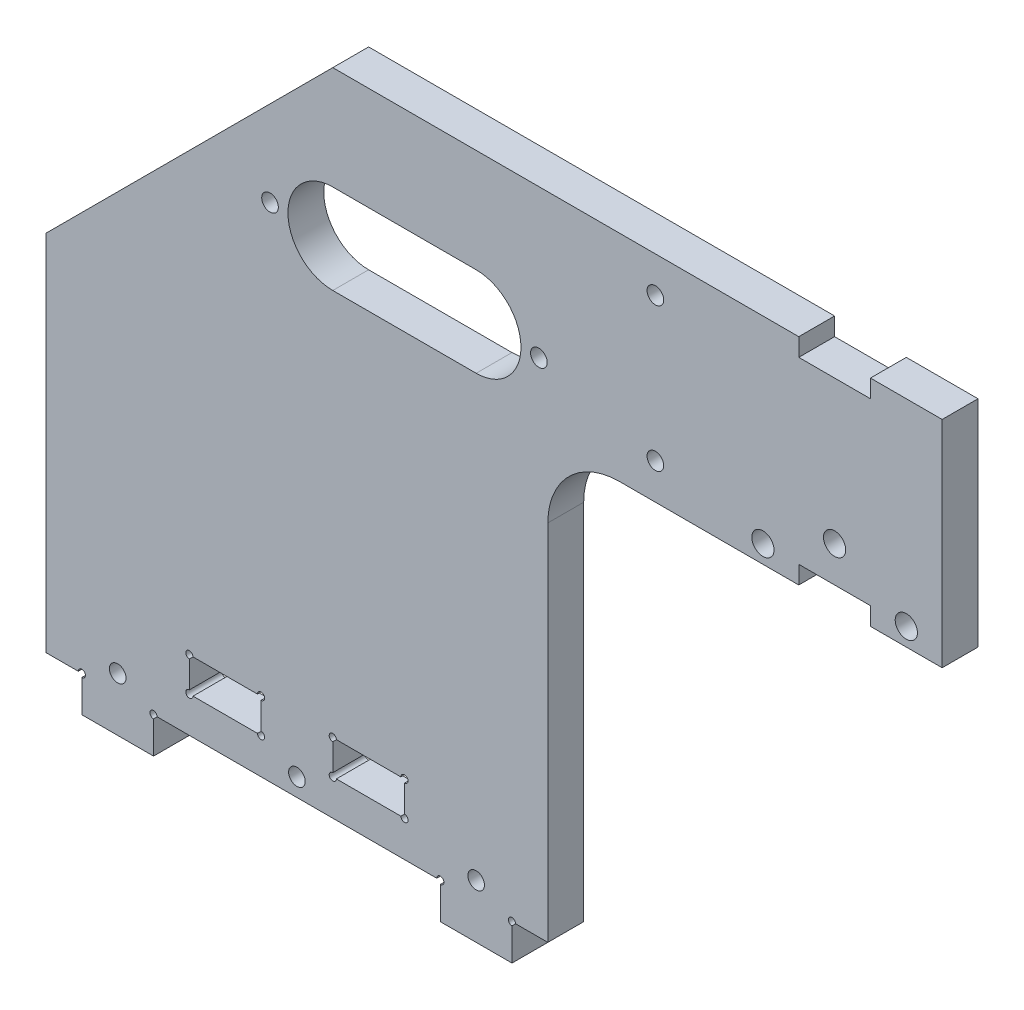
from build123d import *

# Parameters (mm, degrees)
SKETCH1_W                 = 12.7
SKETCH1_H                 = 6.0198
BOSS_EXTRUDE1_DEPTH       = 6.35
SKETCH13_R                = 0.635
CUT_EXTRUDE2_DEPTH        = 6.35
CHAMFER1_SIZE             = 50.8
FILLET2_R                 = 12.7
F_4_CLEARANCE_HOLE1_D     = 2.9464
F_4_CLEARANCE_HOLE1_DEPTH = 6.35
F_4_CLEARANCE_HOLE1_TIP   = 0.885187864
CUT_EXTRUDE3_REACH        = 164.372
SKETCH14_R                = 1.9685
F_4_CLEARANCE_HOLE2_D     = 2.9464
F_4_CLEARANCE_HOLE2_DEPTH = 6.35
F_4_CLEARANCE_HOLE2_TIP   = 0.885187864
CUT_EXTRUDE4_REACH        = 164.372
F_4_CLEARANCE_HOLE3_D     = 2.9464
F_4_CLEARANCE_HOLE3_DEPTH = 6.35
F_4_CLEARANCE_HOLE3_TIP   = 0.885187864


with BuildPart() as part:
    # Sketch1 → Boss-Extrude1 (new body)
    with BuildSketch(Plane.XY):
        Polygon((-25.4, 0), (25.4, 0), (25.4, -6.35), (38.1, -6.35), (38.1, 0), (44.45, 0), (44.45, 77.052), (88.9, 77.052), (88.9, 80.227), (101.6, 80.227), (101.6, 77.052), (114.3, 77.052), (114.3, 115.152), (101.6, 115.152), (101.6, 111.977), (88.9, 111.977), (88.9, 115.152), (-44.45, 115.152), (-44.45, 0), (-38.1, 0), (-38.1, -6.35), (-25.4, -6.35), align=None)
        with Locations((12.7, 9.3599)):
            Rectangle(SKETCH1_W, SKETCH1_H, mode=Mode.SUBTRACT)
        with Locations((-12.7, 9.3599)):
            Rectangle(SKETCH1_W, SKETCH1_H, mode=Mode.SUBTRACT)
    extrude(amount=BOSS_EXTRUDE1_DEPTH)

    # Sketch13 → Cut-Extrude2 (cut)
    with BuildSketch(Plane.XY):
        with Locations((-19.05, 12.3698)):
            Circle(SKETCH13_R)
    cut_extrude2 = extrude(amount=CUT_EXTRUDE2_DEPTH, mode=Mode.SUBTRACT)

    # Sketch-Pattern1: Cut-Extrude2 at 11 more places
    with Locations((12.7, 0, 0), (12.7, -6.0198, 0), (0, -6.0198, 0), (25.4, 0, 0), (38.1, 0, 0), (38.1, -6.0198, 0), (25.4, -6.0198, 0), (57.15, -12.3698, 0), (44.45, -12.3698, 0), (-6.35, -12.3698, 0), (-19.05, -12.3698, 0)):
        add(cut_extrude2, mode=Mode.SUBTRACT)

    # Chamfer1
    chamfer1_edges = [part.edges().sort_by_distance(p)[0] for p in [
        (-44.45, 115.152, 3.175),
    ]]
    chamfer(chamfer1_edges, length=CHAMFER1_SIZE)

    # Fillet2
    fillet2_edges = [part.edges().sort_by_distance(p)[0] for p in [
        (44.45, 77.052, 3.175),
    ]]
    fillet(fillet2_edges, radius=FILLET2_R)

    # #4 Clearance Hole1
    with Locations(Plane.XY.offset(6.35)):
        with Locations((-31.75, 3.175), (31.75, 3.175), (0, 3.175)):
            Hole(F_4_CLEARANCE_HOLE1_D / 2, depth=F_4_CLEARANCE_HOLE1_DEPTH)
            with Locations((0, 0, -(F_4_CLEARANCE_HOLE1_DEPTH + F_4_CLEARANCE_HOLE1_TIP / 2))):  # 118° drill point
                Cone(0, F_4_CLEARANCE_HOLE1_D / 2, F_4_CLEARANCE_HOLE1_TIP, mode=Mode.SUBTRACT)

    # Sketch14 → Cut-Extrude3 (cut, up to next)
    with BuildSketch(Plane.XY.offset(6.35), mode=Mode.PRIVATE) as cut_extrude3_sk1:
        with Locations((95.25, 86.577)):
            Circle(SKETCH14_R)
    cut_extrude3_tool1 = extrude(cut_extrude3_sk1.sketch, amount=-CUT_EXTRUDE3_REACH, mode=Mode.PRIVATE) & part.part
    # Sketch14 → Cut-Extrude3 (cut, up to next)
    with BuildSketch(Plane.XY.offset(6.35), mode=Mode.PRIVATE) as cut_extrude3_sk2:
        with Locations((82.55, 80.227)):
            Circle(SKETCH14_R)
    cut_extrude3_tool2 = extrude(cut_extrude3_sk2.sketch, amount=-CUT_EXTRUDE3_REACH, mode=Mode.PRIVATE) & part.part
    # Sketch14 → Cut-Extrude3 (cut, up to next)
    with BuildSketch(Plane.XY.offset(6.35), mode=Mode.PRIVATE) as cut_extrude3_sk3:
        with Locations((107.95, 80.227)):
            Circle(SKETCH14_R)
    cut_extrude3_tool3 = extrude(cut_extrude3_sk3.sketch, amount=-CUT_EXTRUDE3_REACH, mode=Mode.PRIVATE) & part.part
    add(cut_extrude3_tool1.solids().sort_by_distance((95.25, 86.577, 6.35))[0], mode=Mode.SUBTRACT)
    add(cut_extrude3_tool2.solids().sort_by_distance((82.55, 80.227, 6.35))[0], mode=Mode.SUBTRACT)
    add(cut_extrude3_tool3.solids().sort_by_distance((107.95, 80.227, 6.35))[0], mode=Mode.SUBTRACT)

    # #4 Clearance Hole2
    with Locations(Plane.XY.offset(6.35)):
        with Locations((63.5, 83.402), (63.5, 108.802)):
            Hole(F_4_CLEARANCE_HOLE2_D / 2, depth=F_4_CLEARANCE_HOLE2_DEPTH)
            with Locations((0, 0, -(F_4_CLEARANCE_HOLE2_DEPTH + F_4_CLEARANCE_HOLE2_TIP / 2))):  # 118° drill point
                Cone(0, F_4_CLEARANCE_HOLE2_D / 2, F_4_CLEARANCE_HOLE2_TIP, mode=Mode.SUBTRACT)

    # Sketch18 → Cut-Extrude4 (cut, up to next)
    with BuildSketch(Plane.XY.offset(6.35), mode=Mode.PRIVATE) as cut_extrude4_sk1:
        with BuildLine():
            Line((6.35, 96.8375), (31.75, 96.8375))
            ThreePointArc((31.75, 96.8375), (39.6875, 88.9), (31.75, 80.9625))
            Line((31.75, 80.9625), (6.35, 80.9625))
            ThreePointArc((6.35, 80.9625), (-1.5875, 88.9), (6.35, 96.8375))
        make_face()
    cut_extrude4_tool1 = extrude(cut_extrude4_sk1.sketch, amount=-CUT_EXTRUDE4_REACH, mode=Mode.PRIVATE) & part.part
    add(cut_extrude4_tool1.solids().sort_by_distance((19.05, 88.9, 6.35))[0], mode=Mode.SUBTRACT)

    # #4 Clearance Hole3
    with Locations(Plane.XY.offset(6.35)):
        with Locations((-4.7625, 88.9), (42.8625, 88.9)):
            Hole(F_4_CLEARANCE_HOLE3_D / 2, depth=F_4_CLEARANCE_HOLE3_DEPTH)
            with Locations((0, 0, -(F_4_CLEARANCE_HOLE3_DEPTH + F_4_CLEARANCE_HOLE3_TIP / 2))):  # 118° drill point
                Cone(0, F_4_CLEARANCE_HOLE3_D / 2, F_4_CLEARANCE_HOLE3_TIP, mode=Mode.SUBTRACT)


solid = part.part
